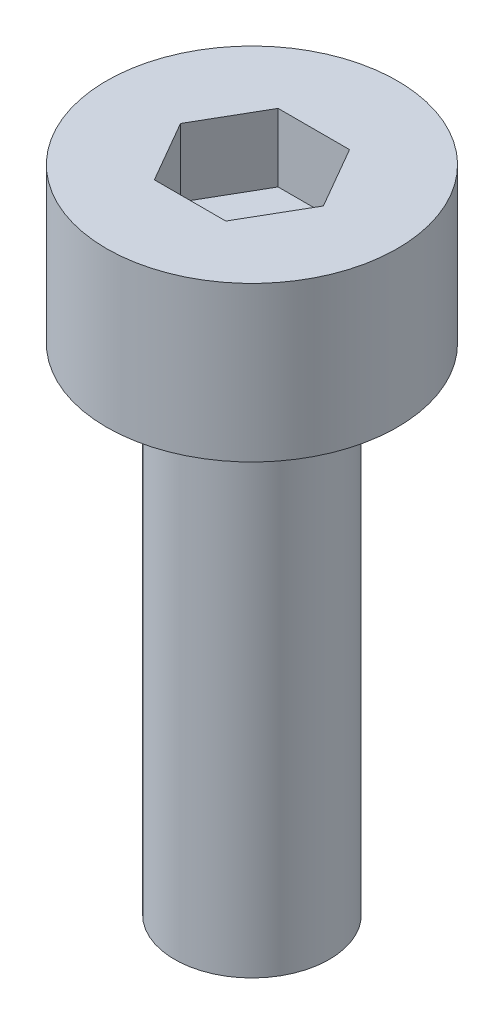
from build123d import *

# Parameters (mm, degrees)
SKETCH_1_R            = 2.35
EXTRUDE_248_DEPTH     = 2.5
CUT_EXTRUDE_382_DEPTH = 1.1
SKETCH_3_R            = 1.25
EXTRUDE_487_DEPTH     = 8


with BuildPart() as part:
    # 草图1 → Extrude 248 (new body)
    with BuildSketch(Plane(origin=(0, 0, 0), x_dir=(1, 0, 0), z_dir=(0, 1, 0))):
        Circle(SKETCH_1_R)
    extrude(amount=EXTRUDE_248_DEPTH)

    # 草图2 → Cut-Extrude 382 (cut)
    with BuildSketch(Plane(origin=(0, 2.5, 0), x_dir=(1, 0, 0), z_dir=(0, 1, 0))):
        Polygon((1.154700538, 0), (0.577350269, 1), (-0.577350269, 1), (-1.154700538, 0), (-0.577350269, -1), (0.577350269, -1), align=None)
    extrude(amount=-CUT_EXTRUDE_382_DEPTH, mode=Mode.SUBTRACT)

    # 草图3 → Extrude 487 (add)
    with BuildSketch(Plane.XZ):
        Circle(SKETCH_3_R)
    extrude(amount=EXTRUDE_487_DEPTH)


solid = part.part
